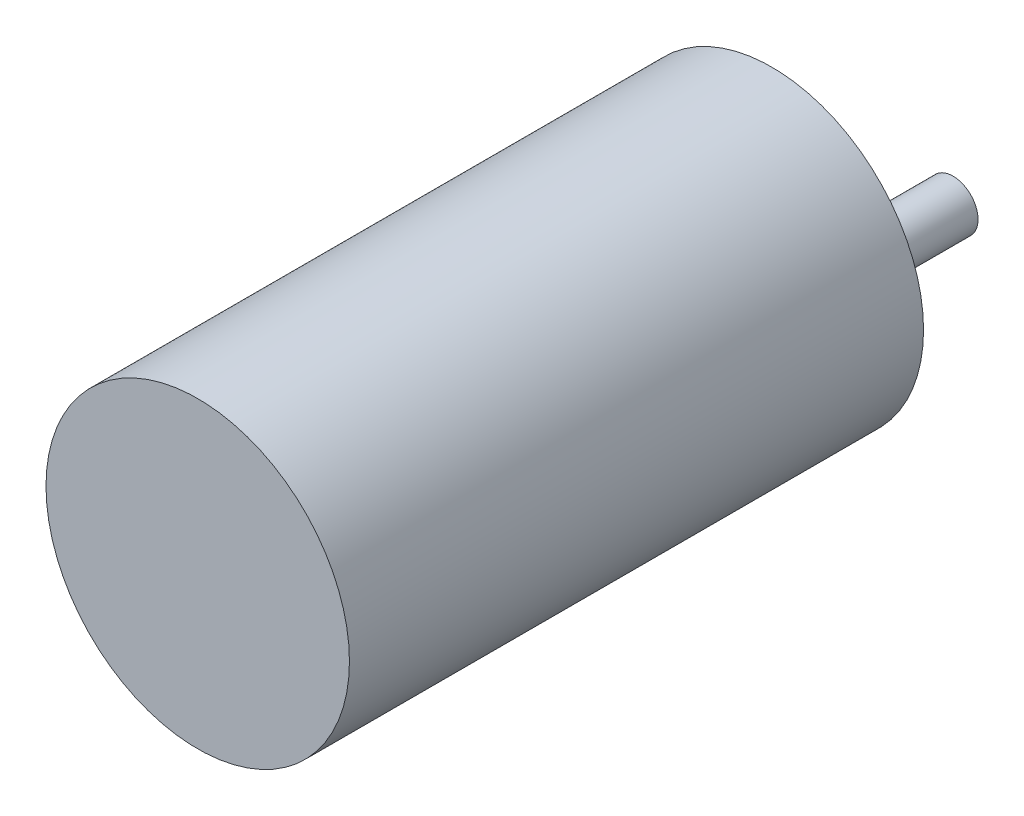
from build123d import *

# Parameters (mm, degrees)
SKETCH1_R           = 18.5
BOSS_EXTRUDE1_DEPTH = 70
SKETCH2_R           = 5.969
BOSS_EXTRUDE2_DEPTH = 6.096
SKETCH3_R           = 3.048
BOSS_EXTRUDE3_DEPTH = 16.002
SKETCH4_R           = 1.6
CUT_EXTRUDE1_DEPTH  = 3


with BuildPart() as part:
    # Sketch1 → Boss-Extrude1 (new body)
    with BuildSketch(Plane.XY):
        Circle(SKETCH1_R)
    extrude(amount=BOSS_EXTRUDE1_DEPTH)

    # Sketch2 → Boss-Extrude2 (add)
    with BuildSketch(Plane(origin=(0, 0, 0), x_dir=(-1, 0, 0), z_dir=(0, 0, -1))):
        with Locations((0, -7.112)):
            Circle(SKETCH2_R)
    extrude(amount=BOSS_EXTRUDE2_DEPTH)

    # Sketch3 → Boss-Extrude3 (add)
    with BuildSketch(Plane(origin=(0, 0, -6.096), x_dir=(-1, 0, 0), z_dir=(0, 0, -1))):
        with Locations((0, -7.112)):
            Circle(SKETCH3_R)
    extrude(amount=BOSS_EXTRUDE3_DEPTH)

    # Sketch4 → Cut-Extrude1 (cut)
    with BuildSketch(Plane(origin=(0, 0, 0), x_dir=(-1, 0, 0), z_dir=(0, 0, -1))):
        with Locations((-15.2766, 0)):
            Circle(SKETCH4_R)
        with Locations((15.2766, 0)):
            Circle(SKETCH4_R)
        with Locations((7.794229315, -13.567540858)):
            Circle(SKETCH4_R)
        with Locations((-7.794229315, -13.567540858)):
            Circle(SKETCH4_R)
        with Locations((-7.794229315, 13.214096537)):
            Circle(SKETCH4_R)
        with Locations((7.794229315, 13.214096537)):
            Circle(SKETCH4_R)
    extrude(amount=-CUT_EXTRUDE1_DEPTH, mode=Mode.SUBTRACT)


solid = part.part
